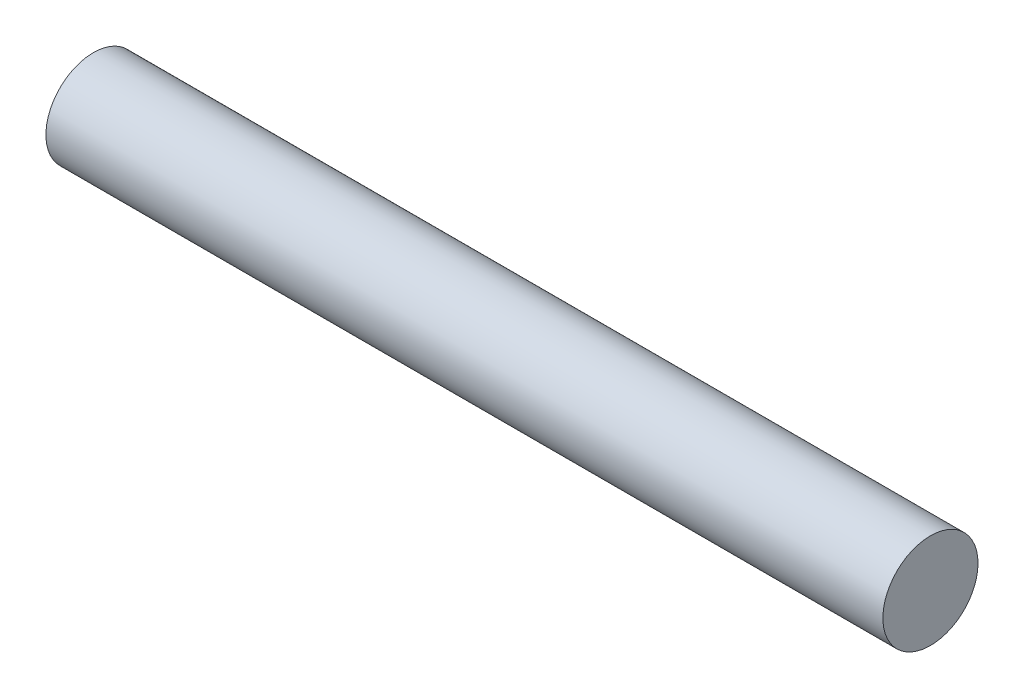
from build123d import *

# Parameters (mm, degrees)
SKETCH1_W = 132
SKETCH1_H = 7.5


with BuildPart() as part:
    # Sketch1 → Revolve1 (revolve)
    with BuildSketch(Plane.XY):
        with Locations((66, 3.75)):
            Rectangle(SKETCH1_W, SKETCH1_H)
    revolve(axis=Axis((0, 0, 0), (-1, 0, 0)))


solid = part.part
